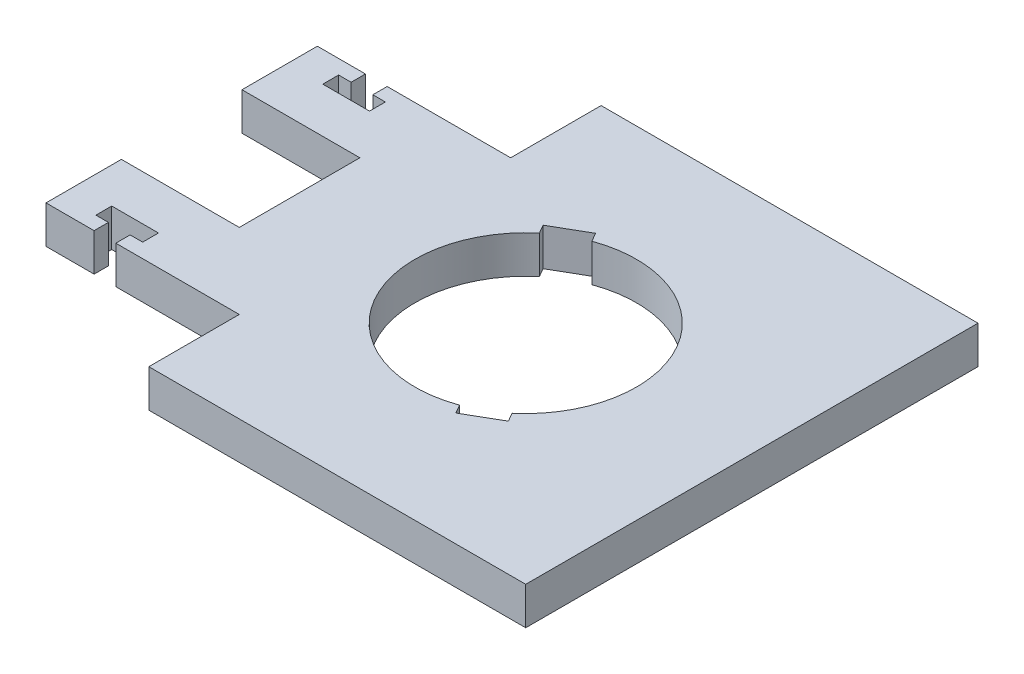
from build123d import *

# Parameters (mm, degrees)
BOSS_EXTRUDE1_DEPTH = 6.35


with BuildPart() as part:
    # Sketch1 → Boss-Extrude1 (new body)
    with BuildSketch(Plane(origin=(0, 0, 0), x_dir=(1, 0, 0), z_dir=(0, 1, 0))):
        Polygon((-25.4, -38.1), (38.1, -38.1), (38.1, 38.1), (-25.4, 38.1), (-25.4, 22.86), (-38.1, 22.86), (-46.2026, 22.86), (-46.2026, 20.447), (-44.0944, 20.447), (-44.0944, 17.78), (-51.9684, 17.78), (-51.9684, 20.447), (-49.8602, 20.447), (-49.8602, 22.86), (-57.9628, 22.86), (-57.9628, 10.16), (-38.1, 10.16), (-38.1, -10.16), (-57.9628, -10.16), (-57.9628, -22.86), (-49.8602, -22.86), (-49.8602, -20.447), (-51.9684, -20.447), (-51.9684, -17.78), (-44.0944, -17.78), (-44.0944, -20.447), (-46.2026, -20.447), (-46.2026, -22.86), (-38.1, -22.86), (-25.4, -22.86), align=None)
        with BuildLine():
            Line((7.227071664, -18.99759929), (12.838867764, -15.757627301))
            Line((12.838867764, -15.757627301), (11.99371709, -14.293783392))
            ThreePointArc((11.99371709, -14.293783392), (16.159242555, 9.329543039), (-6.381920989, 17.533755382))
            Line((-6.381920989, 17.533755382), (-7.227071664, 18.99759929))
            Line((-7.227071664, 18.99759929), (-12.838867764, 15.757627301))
            Line((-12.838867764, 15.757627301), (-11.99371709, 14.293783392))
            ThreePointArc((-11.99371709, 14.293783392), (-16.159242555, -9.329543039), (6.381920989, -17.533755382))
            Line((6.381920989, -17.533755382), (7.227071664, -18.99759929))
        make_face(mode=Mode.SUBTRACT)
    extrude(amount=-BOSS_EXTRUDE1_DEPTH)


solid = part.part
